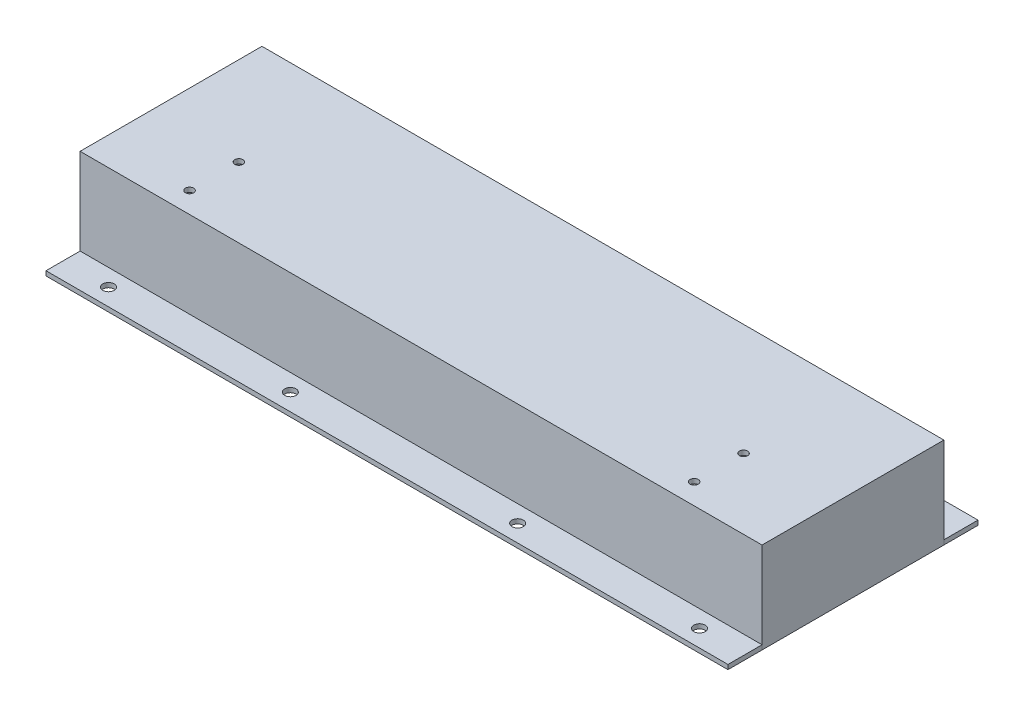
from build123d import *

# Parameters (mm, degrees)
ESBO_O1_W                  = 300
ESBO_O1_H                  = 80
RESSALTO_EXTRUS_O1_DEPTH   = 40
ESBO_O2_W                  = 296
ESBO_O2_H                  = 76
CORTE_EXTRUS_O1_DEPTH      = 38
ESBO_O3_W                  = 300
ESBO_O3_H                  = 15
RESSALTO_EXTRUS_O2_DEPTH   = 2
RESSALTO_EXTRUS_O2_2_DEPTH = 2
ESBO_O4_R                  = 2.5
CORTE_EXTRUS_O2_DEPTH      = 3
ESBO_O5_R                  = 1.8
CORTE_EXTRUS_O3_DEPTH      = 2
ESBO_O6_W                  = 28.5
ESBO_O6_H                  = 22.5
CORTE_EXTRUS_O4_DEPTH      = 2


with BuildPart() as part:
    # Esboço1 → Ressalto-extrusão1 (new body)
    with BuildSketch(Plane(origin=(0, 0, 0), x_dir=(1, 0, 0), z_dir=(0, 1, 0))):
        Rectangle(ESBO_O1_W, ESBO_O1_H)
    extrude(amount=RESSALTO_EXTRUS_O1_DEPTH)

    # Esboço2 → Corte-extrusão1 (cut)
    with BuildSketch(Plane.XZ):
        Rectangle(ESBO_O2_W, ESBO_O2_H)
    extrude(amount=-CORTE_EXTRUS_O1_DEPTH, mode=Mode.SUBTRACT)

    # Esboço5 → Corte-extrusão3 (cut)
    with BuildSketch(Plane(origin=(0, 40, 0), x_dir=(1, 0, 0), z_dir=(0, 1, 0))):
        with Locations((-111, -9.15)):
            Circle(ESBO_O5_R)
        with Locations((111, -9.15)):
            Circle(ESBO_O5_R)
        with Locations((111, -30.85)):
            Circle(ESBO_O5_R)
        with Locations((-111, -30.85)):
            Circle(ESBO_O5_R)
    extrude(amount=-CORTE_EXTRUS_O3_DEPTH, mode=Mode.SUBTRACT)

    # Esboço6 → Corte-extrusão4 (cut)
    with BuildSketch(Plane(origin=(0, 0, -40), x_dir=(-1, 0, 0), z_dir=(0, 0, -1))):
        with Locations((75, 20)):
            Rectangle(ESBO_O6_W, ESBO_O6_H)
    extrude(amount=-CORTE_EXTRUS_O4_DEPTH, mode=Mode.SUBTRACT)


with BuildPart() as body_2:
    # Esboço3 → Ressalto-extrusão2 (new body)
    with BuildSketch(Plane.XZ):
        with Locations((0, 47.5)):
            Rectangle(ESBO_O3_W, ESBO_O3_H)
    extrude(amount=-RESSALTO_EXTRUS_O2_DEPTH)


with BuildPart() as body_3:
    # Esboço3 → Ressalto-extrus_o2 2 (new body)
    with BuildSketch(Plane.XZ):
        with Locations((0, -47.5)):
            Rectangle(ESBO_O3_W, ESBO_O3_H)
    extrude(amount=-RESSALTO_EXTRUS_O2_2_DEPTH)


with BuildPart() as corte_extrus_o2_tool:
    # Esboço4 → Corte-extrusão2 (new body, through all)
    with BuildSketch(Plane(origin=(0, 2, 0), x_dir=(1, 0, 0), z_dir=(0, 1, 0))):
        with Locations((-130, -47.5)):
            Circle(ESBO_O4_R)
        with Locations((-50, -47.5)):
            Circle(ESBO_O4_R)
        with Locations((50, -47.5)):
            Circle(ESBO_O4_R)
        with Locations((130, -47.5)):
            Circle(ESBO_O4_R)
        with Locations((130, 47.5)):
            Circle(ESBO_O4_R)
        with Locations((50, 47.5)):
            Circle(ESBO_O4_R)
        with Locations((-50, 47.5)):
            Circle(ESBO_O4_R)
        with Locations((-130, 47.5)):
            Circle(ESBO_O4_R)
    extrude(amount=-CORTE_EXTRUS_O2_DEPTH)


with BuildPart() as body_2_1:
    add(body_2.part)

    # Corte-extrusão2: cut by corte_extrus_o2_tool
    add(corte_extrus_o2_tool.part, mode=Mode.SUBTRACT)


with BuildPart() as body_3_1:
    add(body_3.part)

    # Corte-extrusão2: cut by corte_extrus_o2_tool
    add(corte_extrus_o2_tool.part, mode=Mode.SUBTRACT)


solid = Compound([part.part, body_2_1.part, body_3_1.part])
